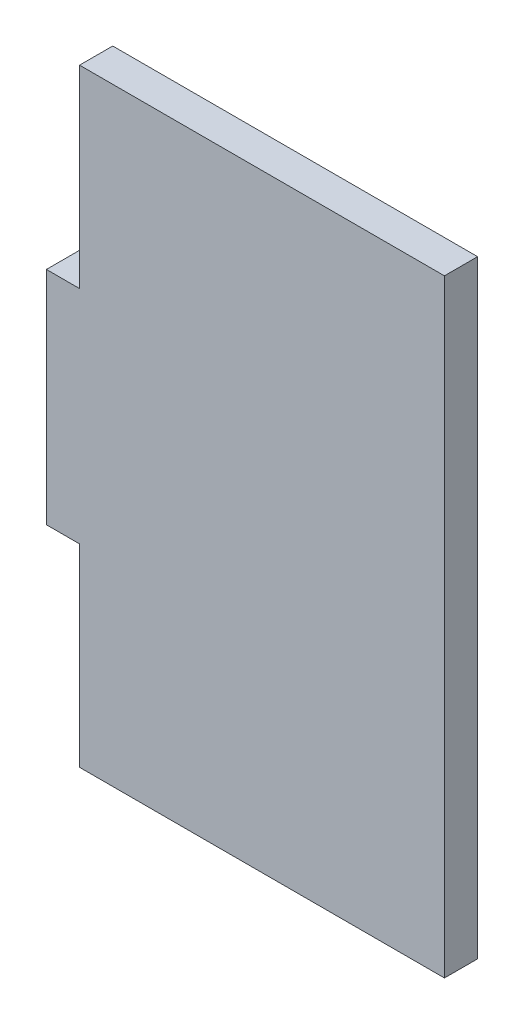
from build123d import *

# Parameters (mm, degrees)
CROQUIS1_W              = 33
CROQUIS1_H              = 55
SALIENTE_EXTRUIR1_DEPTH = 3
CROQUIS2_W              = 3
CROQUIS2_H              = 20
SALIENTE_EXTRUIR2_DEPTH = 3


with BuildPart() as part:
    # Croquis1 → Saliente-Extruir1 (new body)
    with BuildSketch(Plane.XY):
        Rectangle(CROQUIS1_W, CROQUIS1_H)
    extrude(amount=SALIENTE_EXTRUIR1_DEPTH)

    # Croquis2 → Saliente-Extruir2 (add)
    with BuildSketch(Plane.XY.offset(3)):
        with Locations((-18, 0)):
            Rectangle(CROQUIS2_W, CROQUIS2_H)
    extrude(amount=-SALIENTE_EXTRUIR2_DEPTH)


solid = part.part
